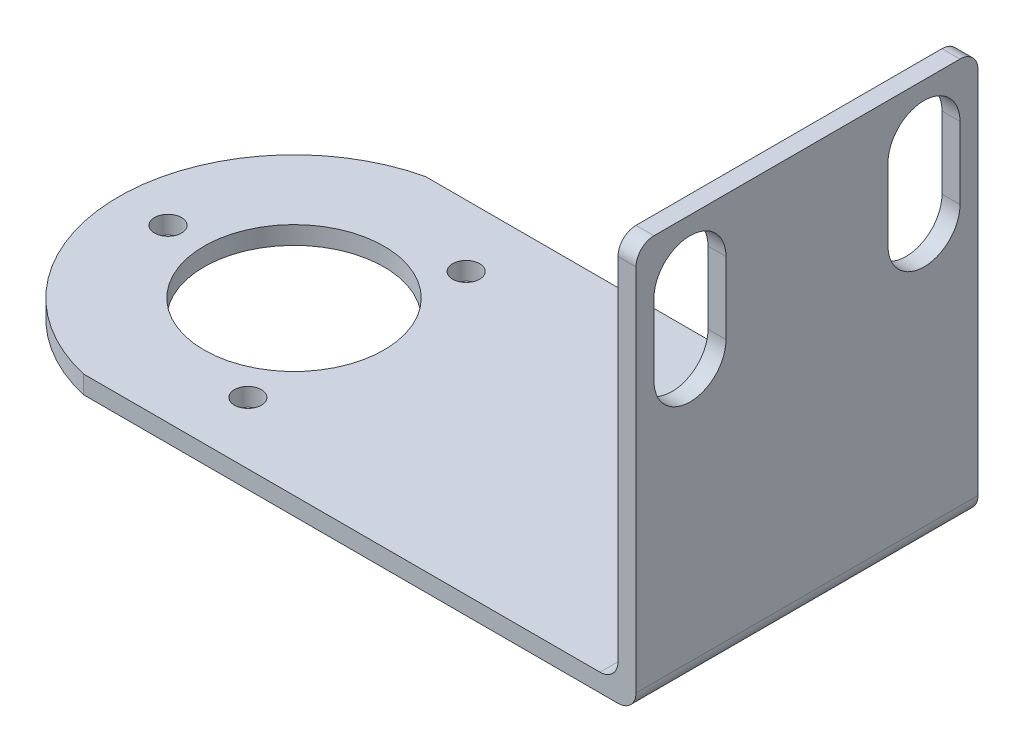
from build123d import *

# Parameters (mm, degrees)
SKETCH1_R           = 1.5
SKETCH1_R_2         = 10
BOSS_EXTRUDE1_DEPTH = 2
SKETCH2_W           = 2
SKETCH2_H           = 38
BOSS_EXTRUDE2_DEPTH = 43
FILLET1_R           = 2
CUT_EXTRUDE1_DEPTH  = 77.5


with BuildPart() as part:
    # Sketch1 → Boss-Extrude1 (new body)
    with BuildSketch(Plane(origin=(0, 0, 0), x_dir=(1, 0, 0), z_dir=(0, 1, 0))):
        with BuildLine():
            Line((0, 0), (61.387482194, 0))
            Line((61.387482194, 0), (61.387482194, 38))
            Line((61.387482194, 38), (0, 38))
            ThreePointArc((0, 38), (-15.112517806, 19), (0, 0))
        make_face()
        with Locations((-9.612517806, 19)):
            Circle(SKETCH1_R, mode=Mode.SUBTRACT)
        with Locations((11.387482194, 31.124355653)):
            Circle(SKETCH1_R, mode=Mode.SUBTRACT)
        with Locations((11.387482194, 6.875644347)):
            Circle(SKETCH1_R, mode=Mode.SUBTRACT)
        with Locations((4.387482194, 19)):
            Circle(SKETCH1_R_2, mode=Mode.SUBTRACT)
    extrude(amount=BOSS_EXTRUDE1_DEPTH)

    # Sketch2 → Boss-Extrude2 (add)
    with BuildSketch(Plane(origin=(0, 2, 0), x_dir=(1, 0, 0), z_dir=(0, 1, 0))):
        with Locations((60.387482194, 19)):
            Rectangle(SKETCH2_W, SKETCH2_H)
    extrude(amount=BOSS_EXTRUDE2_DEPTH)

    # Fillet1
    fillet1_edges = [part.edges().sort_by_distance(p)[0] for p in [
        (61.387482194, 0, -19),
        (59.387482194, 2, -19),
        (60.387482194, 45, -38),
        (60.387482194, 45, 0),
    ]]
    fillet(fillet1_edges, radius=FILLET1_R)

    # Sketch3 → Cut-Extrude1 (cut, through all)
    with BuildSketch(Plane(origin=(61.387482194, 0, 0), x_dir=(0, 0, -1), z_dir=(1, 0, 0))):
        with BuildLine():
            Line((10, 39), (10, 31))
            ThreePointArc((10, 31), (6, 27), (2, 31))
            Line((2, 31), (2, 39))
            ThreePointArc((2, 39), (6, 43), (10, 39))
        make_face()
        with BuildLine():
            Line((36, 39), (36, 31))
            ThreePointArc((36, 31), (32, 27), (28, 31))
            Line((28, 31), (28, 39))
            ThreePointArc((28, 39), (32, 43), (36, 39))
        make_face()
    extrude(amount=-CUT_EXTRUDE1_DEPTH, mode=Mode.SUBTRACT)


solid = part.part
